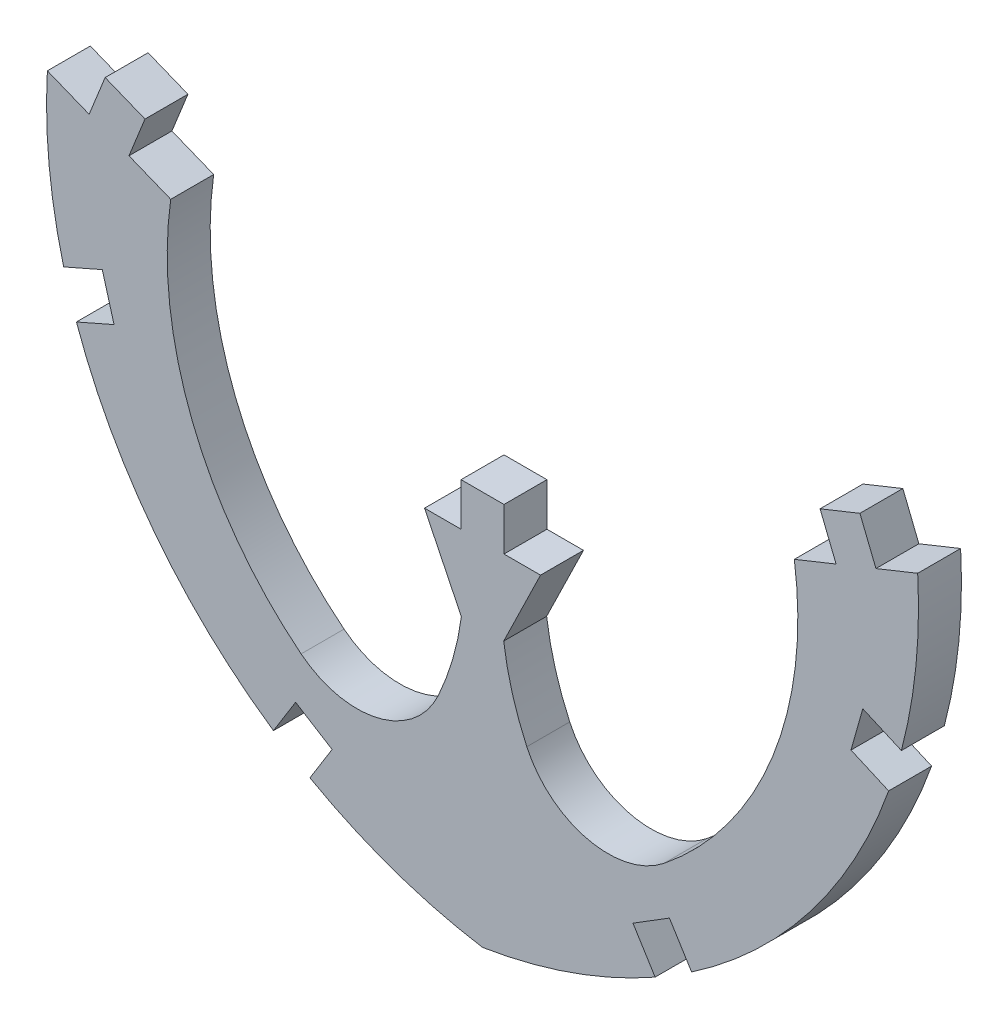
from build123d import *

# Parameters (mm, degrees)
BOSS_EXTRUDE1_DEPTH = 1.524


with BuildPart() as part:
    # Sketch1 → Boss-Extrude1 (new body)
    with BuildSketch(Plane.XY):
        with BuildLine():
            Line((106.811293612, -4.205619723), (105.503930304, -1.524))
            Line((105.503930304, -1.524), (106.800157748, -1.524))
            Line((106.800157748, -1.524), (106.800157748, 0))
            Line((106.800157748, 0), (108.32415775, 0))
            Line((108.32415775, 0), (108.32415775, -1.524))
            Line((108.32415775, -1.524), (109.620385194, -1.524))
            Line((109.620385194, -1.524), (108.313021885, -4.205619723))
            ThreePointArc((108.313021885, -4.205619723), (108.616799976, -5.654511508), (109.13336302, -7.041858312))
            ThreePointArc((109.13336302, -7.041858312), (111.286278886, -8.804119786), (114.000740009, -8.193945187))
            ThreePointArc((114.000740009, -8.193945187), (117.860186741, -2.977615774), (118.628372854, 3.4656219))
            Line((118.628372854, 3.4656219), (120.110575877, 4.061475664))
            Line((120.110575877, 4.061475664), (119.542132666, 5.475494164))
            Line((119.542132666, 5.475494164), (120.956151165, 6.043937374))
            Line((120.956151165, 6.043937374), (121.524594376, 4.629918875))
            Line((121.524594376, 4.629918875), (123.006797398, 5.225772639))
            ThreePointArc((123.006797398, 5.225772639), (122.943528087, 2.333705851), (122.428113191, -0.512765789))
            Line((122.428113191, -0.512765789), (121.057887131, 0.088329507))
            Line((121.057887131, 0.088329507), (120.639136812, -1.392165095))
            Line((120.639136812, -1.392165095), (121.97564456, -1.97846873))
            ThreePointArc((121.97564456, -1.97846873), (119.201094938, -7.067703715), (114.981972786, -11.042303895))
            Line((114.981972786, -11.042303895), (114.195536637, -9.777044843))
            Line((114.195536637, -9.777044843), (112.901190835, -10.581560192))
            Line((112.901190835, -10.581560192), (113.687626985, -11.846819244))
            ThreePointArc((113.687626985, -11.846819244), (110.720377701, -13.193789782), (107.562157749, -13.996625182))
            ThreePointArc((107.562157749, -13.996625182), (104.403937797, -13.193789782), (101.436688513, -11.846819244))
            Line((101.436688513, -11.846819244), (102.223124662, -10.581560192))
            Line((102.223124662, -10.581560192), (100.928778861, -9.777044843))
            Line((100.928778861, -9.777044843), (100.142342712, -11.042303895))
            ThreePointArc((100.142342712, -11.042303895), (95.923220559, -7.067703715), (93.148670938, -1.97846873))
            Line((93.148670938, -1.97846873), (94.485178686, -1.392165095))
            Line((94.485178686, -1.392165095), (94.066428367, 0.088329507))
            Line((94.066428367, 0.088329507), (92.696202307, -0.512765789))
            ThreePointArc((92.696202307, -0.512765789), (92.18078741, 2.333705851), (92.117518099, 5.225772639))
            Line((92.117518099, 5.225772639), (93.599721122, 4.629918875))
            Line((93.599721122, 4.629918875), (94.168164333, 6.043937374))
            Line((94.168164333, 6.043937374), (95.582182832, 5.475494164))
            Line((95.582182832, 5.475494164), (95.013739621, 4.061475664))
            Line((95.013739621, 4.061475664), (96.495942644, 3.4656219))
            ThreePointArc((96.495942644, 3.4656219), (97.264128757, -2.977615774), (101.123575488, -8.193945187))
            ThreePointArc((101.123575488, -8.193945187), (103.838036611, -8.804119786), (105.990952478, -7.041858312))
            ThreePointArc((105.990952478, -7.041858312), (106.507515522, -5.654511508), (106.811293612, -4.205619723))
        make_face()
    extrude(amount=BOSS_EXTRUDE1_DEPTH)


solid = part.part
